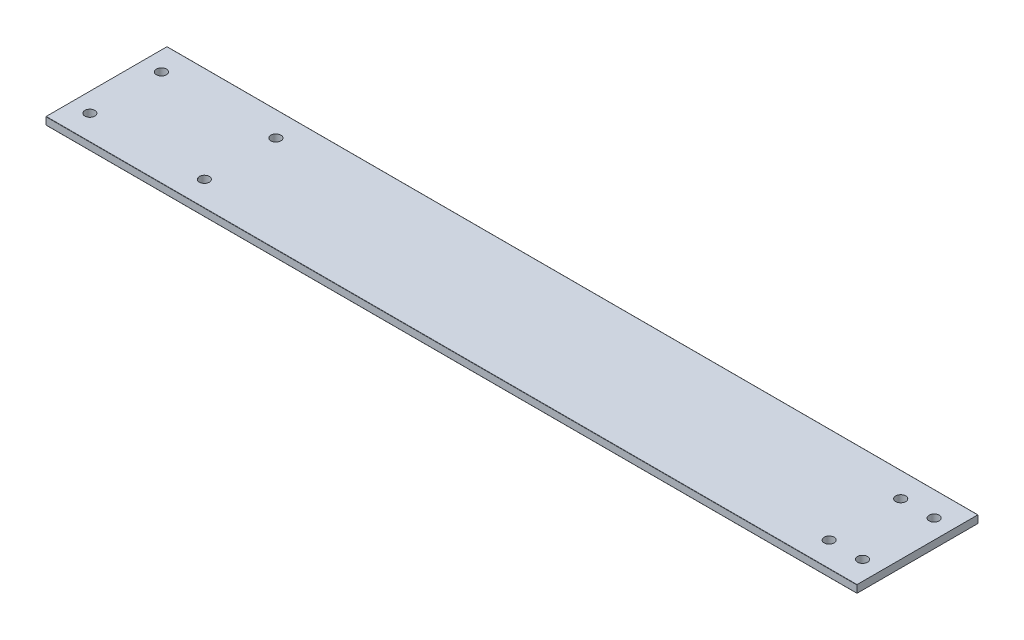
from build123d import *

# Parameters (mm, degrees)
SKETCH3_W                = 609.6
SKETCH3_H                = 50.8
BOSS_EXTRUDE1_DEPTH      = 1.5875
BOSS_EXTRUDE1_DEPTH_BACK = 1.5875
FILLET1_R                = 0.104775
CUT_EXTRUDE1_START       = -269.6
SKETCH4_W                = 50.8
SKETCH4_H                = 3.175
CUT_EXTRUDE1_DEPTH       = 269.6
SKETCH5_R                = 2.1
CUT_EXTRUDE2_DEPTH       = 4.175


with BuildPart() as part:
    # Sketch3 → Boss-Extrude1 (new body, two sides)
    with BuildSketch(Plane(origin=(0, 0, 0), x_dir=(1, 0, 0), z_dir=(0, 1, 0))) as boss_extrude1_sk:
        Rectangle(SKETCH3_W, SKETCH3_H)
    extrude(amount=BOSS_EXTRUDE1_DEPTH)
    extrude(boss_extrude1_sk.sketch, amount=-BOSS_EXTRUDE1_DEPTH_BACK)

    # Fillet1
    fillet1_edges = [part.edges().sort_by_distance(p)[0] for p in [
        (0, 1.5875, 25.4),
        (0, -1.5875, -25.4),
        (0, 1.5875, -25.4),
        (0, -1.5875, 25.4),
    ]]
    fillet(fillet1_edges, radius=FILLET1_R)

    # Sketch4 → Cut-Extrude1 (cut)
    with BuildSketch(Plane(origin=(304.8, 0, 0), x_dir=(0, 0, -1), z_dir=(1, 0, 0)).offset(CUT_EXTRUDE1_START)):
        Rectangle(SKETCH4_W, SKETCH4_H)
    extrude(amount=CUT_EXTRUDE1_DEPTH, mode=Mode.SUBTRACT)

    # Sketch5 → Cut-Extrude2 (cut, through all)
    with BuildSketch(Plane.XZ.offset(1.5875)):
        with Locations((27.2, -15)):
            Circle(SKETCH5_R)
        with Locations((27.2, 15)):
            Circle(SKETCH5_R)
        with Locations((13.199, 15)):
            Circle(SKETCH5_R)
        with Locations((13.199, -15)):
            Circle(SKETCH5_R)
        with Locations((-248.8, -15)):
            Circle(SKETCH5_R)
        with Locations((-248.8, 15)):
            Circle(SKETCH5_R)
        with Locations((-296.8, 15)):
            Circle(SKETCH5_R)
        with Locations((-296.8, -15)):
            Circle(SKETCH5_R)
    extrude(amount=-CUT_EXTRUDE2_DEPTH, mode=Mode.SUBTRACT)


solid = part.part
